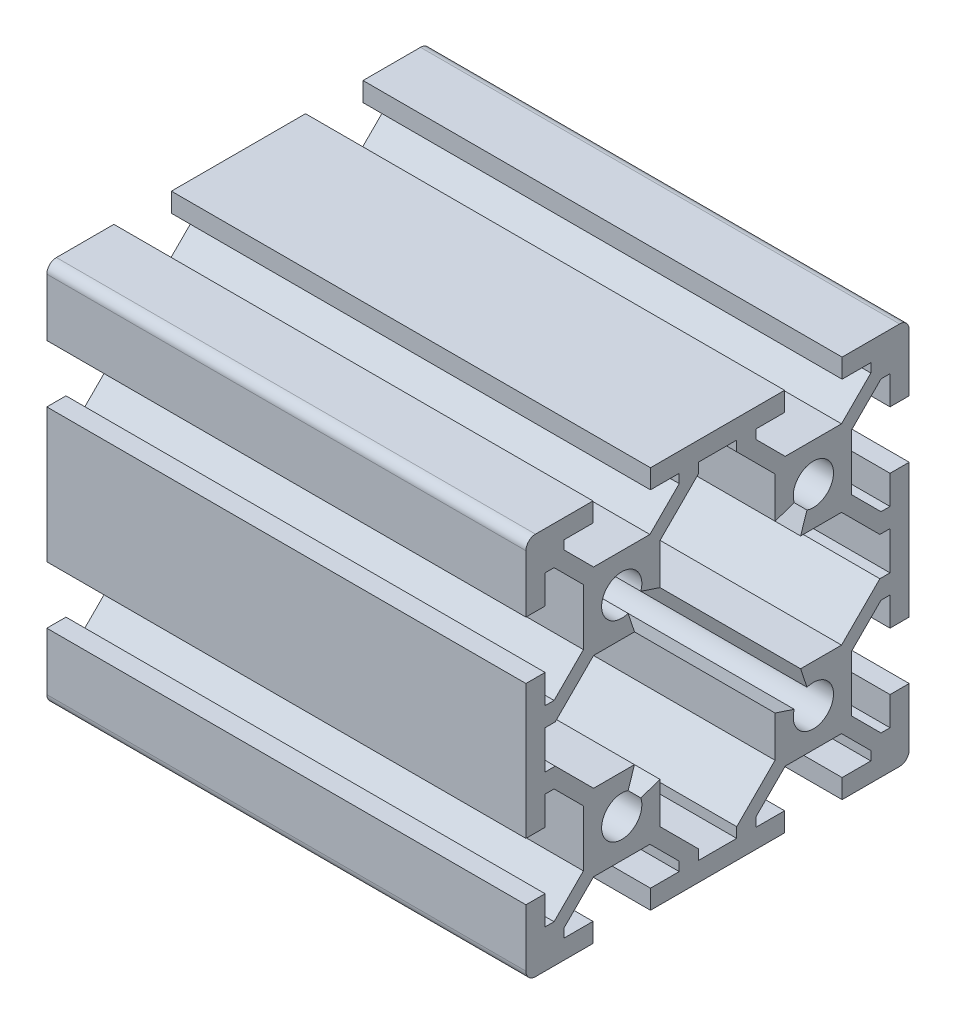
from build123d import *

# Parameters (mm, degrees)
BOSS_EXTRUDE1_DEPTH = 50


with BuildPart() as part:
    # Sketch1 → Boss-Extrude1 (new body)
    with BuildSketch(Plane(origin=(0, 0, 0), x_dir=(0, 0, -1), z_dir=(1, 0, 0))):
        with BuildLine():
            Line((-20, 19), (-20, 13))
            Line((-20, 13), (-18, 13))
            Line((-18, 13), (-18, 16))
            Line((-18, 16), (-17.060660172, 16))
            Line((-17.060660172, 16), (-14, 12.939339828))
            Line((-14, 12.939339828), (-14, 7.060660172))
            Line((-14, 7.060660172), (-17.060660172, 4))
            Line((-17.060660172, 4), (-18, 4))
            Line((-18, 4), (-18, 7))
            Line((-18, 7), (-20, 7))
            Line((-20, 7), (-20, -7))
            Line((-20, -7), (-18, -7))
            Line((-18, -7), (-18, -4))
            Line((-18, -4), (-17.060660172, -4))
            Line((-17.060660172, -4), (-14, -7.060660172))
            Line((-14, -7.060660172), (-14, -12.939339828))
            Line((-14, -12.939339828), (-17.060660172, -16))
            Line((-17.060660172, -16), (-18, -16))
            Line((-18, -16), (-18, -13))
            Line((-18, -13), (-20, -13))
            Line((-20, -13), (-20, -19))
            ThreePointArc((-20, -19), (-19.707106781, -19.707106781), (-19, -20))
            Line((-19, -20), (-13, -20))
            Line((-13, -20), (-13, -18))
            Line((-13, -18), (-16, -18))
            Line((-16, -18), (-16, -17.060660172))
            Line((-16, -17.060660172), (-12.939339828, -14))
            Line((-12.939339828, -14), (-7.060660172, -14))
            Line((-7.060660172, -14), (-4, -17.060660172))
            Line((-4, -17.060660172), (-4, -18))
            Line((-4, -18), (-7, -18))
            Line((-7, -18), (-7, -20))
            Line((-7, -20), (7, -20))
            Line((7, -20), (7, -18))
            Line((7, -18), (4, -18))
            Line((4, -18), (4, -17.060660172))
            Line((4, -17.060660172), (7.060660172, -14))
            Line((7.060660172, -14), (12.939339828, -14))
            Line((12.939339828, -14), (16, -17.060660172))
            Line((16, -17.060660172), (16, -18))
            Line((16, -18), (13, -18))
            Line((13, -18), (13, -20))
            Line((13, -20), (19, -20))
            ThreePointArc((19, -20), (19.707106781, -19.707106781), (20, -19))
            Line((20, -19), (20, -13))
            Line((20, -13), (18, -13))
            Line((18, -13), (18, -16))
            Line((18, -16), (17.060660172, -16))
            Line((17.060660172, -16), (14, -12.939339828))
            Line((14, -12.939339828), (14, -7.060660172))
            Line((14, -7.060660172), (17.060660172, -4))
            Line((17.060660172, -4), (18, -4))
            Line((18, -4), (18, -7))
            Line((18, -7), (20, -7))
            Line((20, -7), (20, 7))
            Line((20, 7), (18, 7))
            Line((18, 7), (18, 4))
            Line((18, 4), (17.060660172, 4))
            Line((17.060660172, 4), (14, 7.060660172))
            Line((14, 7.060660172), (14, 12.939339828))
            Line((14, 12.939339828), (17.060660172, 16))
            Line((17.060660172, 16), (18, 16))
            Line((18, 16), (18, 13))
            Line((18, 13), (20, 13))
            Line((20, 13), (20, 19))
            ThreePointArc((20, 19), (19.707106781, 19.707106781), (19, 20))
            Line((19, 20), (13, 20))
            Line((13, 20), (13, 18))
            Line((13, 18), (16, 18))
            Line((16, 18), (16, 17.060660172))
            Line((16, 17.060660172), (12.939339828, 14))
            Line((12.939339828, 14), (7.060660172, 14))
            Line((7.060660172, 14), (4, 17.060660172))
            Line((4, 17.060660172), (4, 18))
            Line((4, 18), (7, 18))
            Line((7, 18), (7, 20))
            Line((7, 20), (-7, 20))
            Line((-7, 20), (-7, 18))
            Line((-7, 18), (-4, 18))
            Line((-4, 18), (-4, 17.060660172))
            Line((-4, 17.060660172), (-7.060660172, 14))
            Line((-7.060660172, 14), (-12.939339828, 14))
            Line((-12.939339828, 14), (-16, 17.060660172))
            Line((-16, 17.060660172), (-16, 18))
            Line((-16, 18), (-13, 18))
            Line((-13, 18), (-13, 20))
            Line((-13, 20), (-19, 20))
            ThreePointArc((-19, 20), (-19.707106781, 19.707106781), (-20, 19))
        make_face()
        with BuildLine():
            Line((-16.939339828, 2), (-18, 2))
            Line((-18, 2), (-18, -2))
            Line((-18, -2), (-16.939339828, -2))
            Line((-16.939339828, -2), (-12.939339828, -6))
            Line((-12.939339828, -6), (-8.666662697, -6))
            Line((-8.666662697, -6), (-9.335919912, -8.007765667))
            ThreePointArc((-9.335919912, -8.007765667), (-11.48492424, -11.48492424), (-8.007765667, -9.335919912))
            Line((-8.007765667, -9.335919912), (-6, -8.666662697))
            Line((-6, -8.666662697), (-6, -12.939339828))
            Line((-6, -12.939339828), (-2, -16.939339828))
            Line((-2, -16.939339828), (-2, -18))
            Line((-2, -18), (2, -18))
            Line((2, -18), (2, -16.939339828))
            Line((2, -16.939339828), (6, -12.939339828))
            Line((6, -12.939339828), (6, -8.666662697))
            Line((6, -8.666662697), (8.007765667, -9.335919912))
            ThreePointArc((8.007765667, -9.335919912), (11.48492424, -11.48492424), (9.335919912, -8.007765667))
            Line((9.335919912, -8.007765667), (8.666662697, -6))
            Line((8.666662697, -6), (12.939339828, -6))
            Line((12.939339828, -6), (16.939339828, -2))
            Line((16.939339828, -2), (18, -2))
            Line((18, -2), (18, 2))
            Line((18, 2), (16.939339828, 2))
            Line((16.939339828, 2), (12.939339828, 6))
            Line((12.939339828, 6), (8.666662697, 6))
            Line((8.666662697, 6), (9.335919912, 8.007765667))
            ThreePointArc((9.335919912, 8.007765667), (11.48492424, 11.48492424), (8.007765667, 9.335919912))
            Line((8.007765667, 9.335919912), (6, 8.666662697))
            Line((6, 8.666662697), (6, 12.939339828))
            Line((6, 12.939339828), (2, 16.939339828))
            Line((2, 16.939339828), (2, 18))
            Line((2, 18), (-2, 18))
            Line((-2, 18), (-2, 16.939339828))
            Line((-2, 16.939339828), (-6, 12.939339828))
            Line((-6, 12.939339828), (-6, 8.666662697))
            Line((-6, 8.666662697), (-8.007765667, 9.335919912))
            ThreePointArc((-8.007765667, 9.335919912), (-11.48492424, 11.48492424), (-9.335919912, 8.007765667))
            Line((-9.335919912, 8.007765667), (-8.666662697, 6))
            Line((-8.666662697, 6), (-12.939339828, 6))
            Line((-12.939339828, 6), (-16.939339828, 2))
        make_face(mode=Mode.SUBTRACT)
    extrude(amount=BOSS_EXTRUDE1_DEPTH)


solid = part.part
